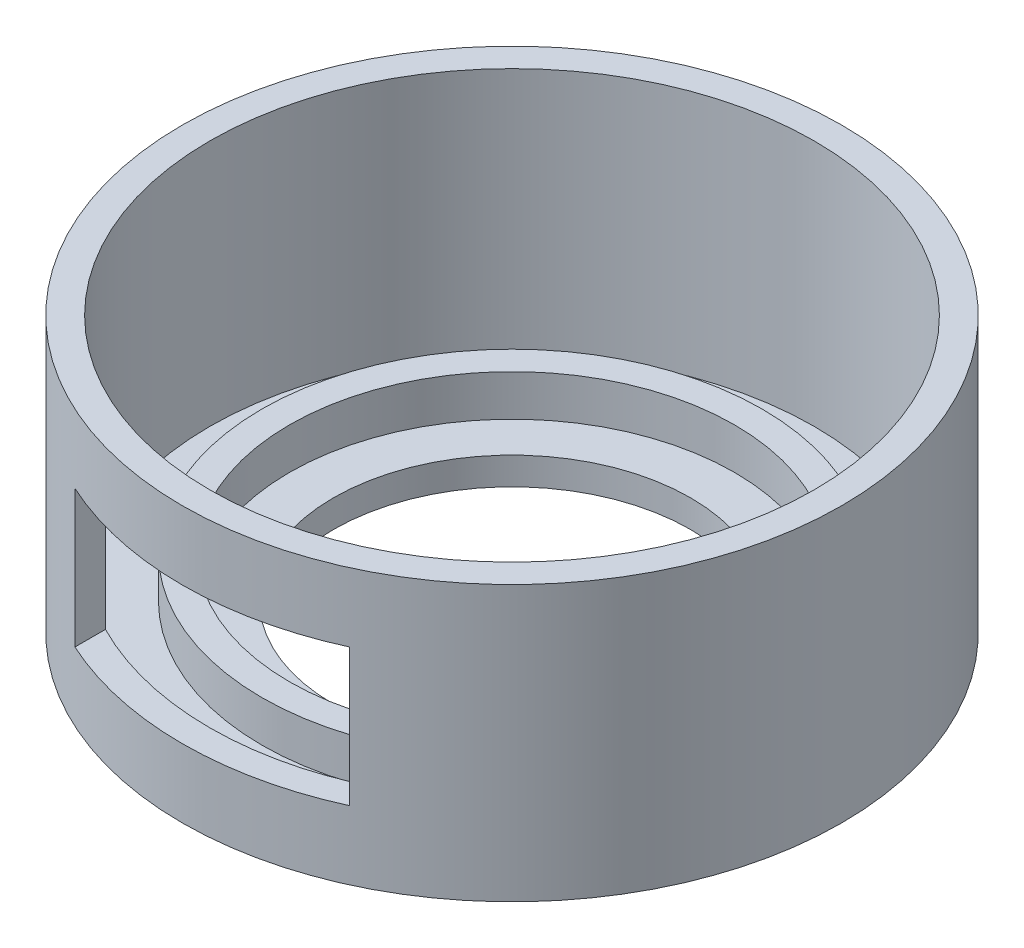
from build123d import *

# Parameters (mm, degrees)
CROQUIS1_R              = 11
CROQUIS1_R_2            = 6.5
SALIENTE_EXTRUIR2_DEPTH = 1
CROQUIS1_6_R            = 9.1
CROQUIS1_6_R_2          = 8.1
SALIENTE_EXTRUIR3_DEPTH = 2.5
CROQUIS1_8_R            = 12
CROQUIS1_8_R_2          = 11
SALIENTE_EXTRUIR4_DEPTH = 10
CROQUIS10_W             = 10
CROQUIS10_H             = 5
CORTAR_EXTRUIR1_DEPTH   = 30


with BuildPart() as part:
    # Croquis1 → Saliente-Extruir2 (new body)
    with BuildSketch(Plane(origin=(0, 0, 0), x_dir=(1, 0, 0), z_dir=(0, 1, 0))):
        with Locations((8.8, 6.6)):
            Circle(CROQUIS1_R)
        with Locations((8.8, 6.6)):
            Circle(CROQUIS1_R_2, mode=Mode.SUBTRACT)
    extrude(amount=SALIENTE_EXTRUIR2_DEPTH)

    # Croquis1_6 → Saliente-Extruir3 (add)
    with BuildSketch(Plane(origin=(0, 0, 0), x_dir=(1, 0, 0), z_dir=(0, 1, 0))):
        with Locations((8.8, 6.6)):
            Circle(CROQUIS1_6_R)
        with Locations((8.8, 6.6)):
            Circle(CROQUIS1_6_R_2, mode=Mode.SUBTRACT)
    extrude(amount=SALIENTE_EXTRUIR3_DEPTH)

    # Croquis1_8 → Saliente-Extruir4 (add)
    with BuildSketch(Plane(origin=(0, 0, 0), x_dir=(1, 0, 0), z_dir=(0, 1, 0))):
        with Locations((8.8, 6.6)):
            Circle(CROQUIS1_8_R)
        with Locations((8.8, 6.6)):
            Circle(CROQUIS1_8_R_2, mode=Mode.SUBTRACT)
    extrude(amount=SALIENTE_EXTRUIR4_DEPTH)

    # Croquis10 → Cortar-Extruir1 (cut)
    with BuildSketch(Plane.XY):
        with Locations((8.8, 5)):
            Rectangle(CROQUIS10_W, CROQUIS10_H)
    extrude(amount=CORTAR_EXTRUIR1_DEPTH, mode=Mode.SUBTRACT)


solid = part.part
